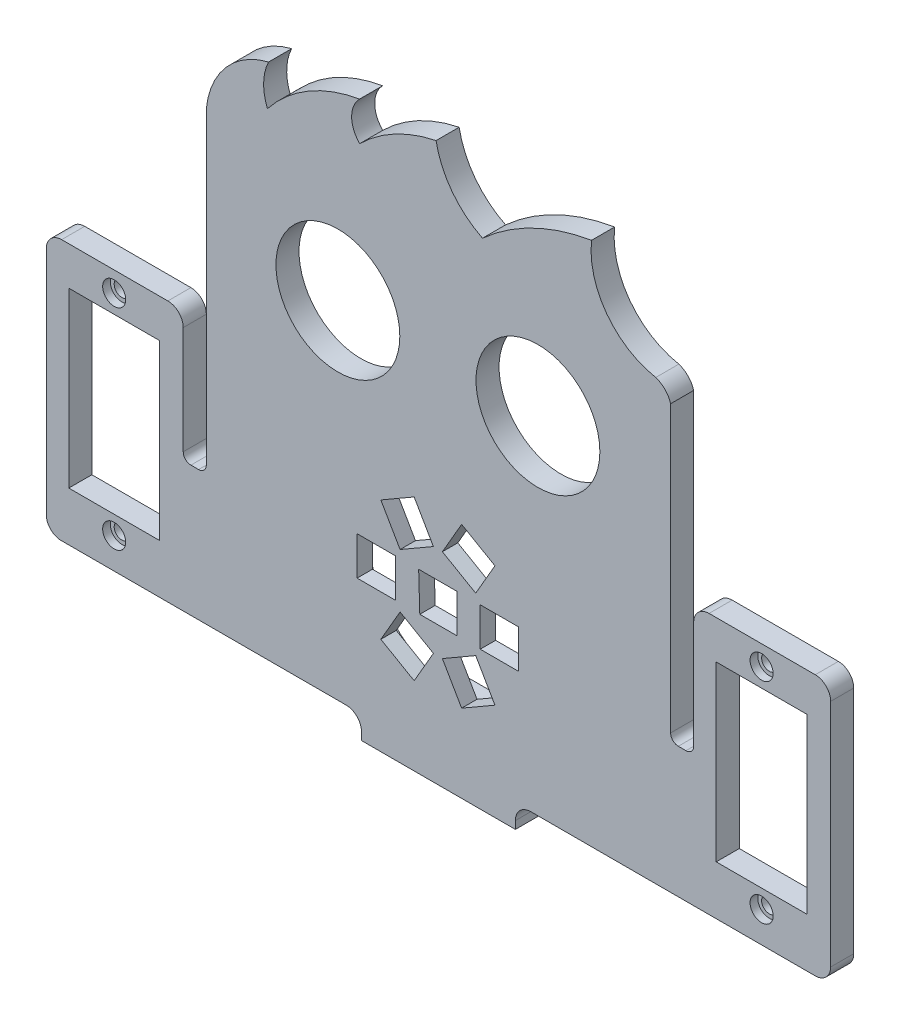
from build123d import *

# Parameters (mm, degrees)
MODEL_R                 = 8.05
MODEL_R_2               = 1
MODEL_W                 = 5
MODEL_H                 = 5
MODEL_W_2               = 11.8
MODEL_H_2               = 22.5
SALIENTE_EXTRUIR1_DEPTH = 3
CROQUIS2_R              = 1.5
CORTAR_EXTRUIR1_DEPTH   = 1
CROQUIS4_W              = 19.999967436
CROQUIS4_H              = 3
SALIENTE_EXTRUIR2_DEPTH = 8
CROQUIS5_R              = 1.5
CORTAR_EXTRUIR2_DEPTH   = 3
REDONDEO1_R             = 2
CROQUIS6_R              = 12
CORTAR_EXTRUIR3_DEPTH   = 1


with BuildPart() as part:
    # Model → Saliente-Extruir1 (new body)
    with BuildSketch(Plane.XY):
        with BuildLine():
            Line((28.600020379, -36.098945331), (29.600020379, -36.098945331))
            ThreePointArc((29.600020379, -36.098945331), (30.307127161, -35.806052112), (30.600020379, -35.098945331))
            Line((30.600020379, -35.098945331), (30.600020379, 4.974420659))
            ThreePointArc((30.600020379, 4.974420659), (33.150320304, 10.94136051), (38.69115159, 14.318872844))
            ThreePointArc((38.69115159, 14.318872844), (38.049426695, 11.673196605), (38.544127303, 8.99613013))
            ThreePointArc((38.544127303, 8.99613013), (43.872924224, 13.634815248), (50.51172433, 16.051385009))
            ThreePointArc((50.51172433, 16.051385009), (49.487728366, 13.546636971), (50.534778199, 11.051438157))
            ThreePointArc((50.534778199, 11.051438157), (55.112285588, 14.426569266), (60.460332405, 16.361376528))
            ThreePointArc((60.460332405, 16.361376528), (62.537747107, 11.66270114), (66.497154818, 8.389126209))
            ThreePointArc((66.497154818, 8.389126209), (73.089038309, 12.831206377), (80.665288642, 15.236499516))
            ThreePointArc((80.665288642, 15.236499516), (82.62970299, 7.967186508), (89.013428278, 3.973455574))
            ThreePointArc((89.013428278, 3.973455574), (90.223089011, 3.212884764), (90.943701038, 1.979002536))
            Line((90.943701038, 1.979002536), (90.943701038, -35.070997464))
            ThreePointArc((90.943701038, -35.070997464), (91.236594257, -35.778104245), (91.943701038, -36.070997464))
            Line((91.943701038, -36.070997464), (92.943701038, -36.070997464))
            ThreePointArc((92.943701038, -36.070997464), (93.650807819, -35.778104245), (93.943701038, -35.070997464))
            Line((93.943701038, -35.070997464), (93.943701038, -21.120997464))
            ThreePointArc((93.943701038, -21.120997464), (94.529487475, -19.706783901), (95.943701038, -19.120997464))
            Line((95.943701038, -19.120997464), (109.743701038, -19.120997464))
            ThreePointArc((109.743701038, -19.120997464), (111.1579146, -19.706783901), (111.743701038, -21.120997464))
            Line((111.743701038, -21.120997464), (111.743701038, -51.020997464))
            ThreePointArc((111.743701038, -51.020997464), (111.1579146, -52.435211026), (109.743701038, -53.020997464))
            Line((109.743701038, -53.020997464), (72.771860709, -53.020997464))
            ThreePointArc((72.771860709, -53.020997464), (71.357647146, -53.606783901), (70.771860709, -55.020997464))
            Line((70.771860709, -55.020997464), (70.771860709, -56.020573856))
            Line((70.771860709, -56.020573856), (50.771893273, -56.020573856))
            Line((50.771893273, -56.020573856), (50.771882418, -55.020552149))
            ThreePointArc((50.771882418, -55.020552149), (50.186088306, -53.606352619), (48.771882419, -53.020573857))
            Line((48.771882419, -53.020573857), (11.743679941, -53.020573857))
            ThreePointArc((11.743679941, -53.020573857), (10.369303805, -52.451275514), (9.800020379, -51.076893199))
            Line((9.800020379, -51.076893199), (9.800020379, -21.120997464))
            ThreePointArc((9.800020379, -21.120997464), (10.385806817, -19.706783901), (11.800020379, -19.120997464))
            Line((11.800020379, -19.120997464), (25.600020379, -19.120997464))
            ThreePointArc((25.600020379, -19.120997464), (27.014233942, -19.706783901), (27.600020379, -21.120997464))
            Line((27.600020379, -21.120997464), (27.600020379, -35.098945331))
            ThreePointArc((27.600020379, -35.098945331), (27.892913598, -35.806052112), (28.600020379, -36.098945331))
        make_face()
        with Locations((47.698959583, -8.020997464)):
            Circle(MODEL_R, mode=Mode.SUBTRACT)
        with Locations((73.698959582, -8.020997464)):
            Circle(MODEL_R, mode=Mode.SUBTRACT)
        with Locations((102.770799912, -49.020997464)):
            Circle(MODEL_R_2, mode=Mode.SUBTRACT)
        with Locations((102.770799912, -21.720997464)):
            Circle(MODEL_R_2, mode=Mode.SUBTRACT)
        with Locations((18.627119253, -49.020997464)):
            Circle(MODEL_R_2, mode=Mode.SUBTRACT)
        with Locations((18.627119253, -21.720997464)):
            Circle(MODEL_R_2, mode=Mode.SUBTRACT)
        Polygon((53.283896073, -43.364264203), (57.614023092, -45.864264203), (60.114023092, -41.534137185), (55.783896073, -39.034137185), align=None, mode=Mode.SUBTRACT)
        Polygon((63.783896073, -45.864264204), (68.114023092, -43.364264204), (65.614023092, -39.034137185), (61.283896073, -41.534137185), align=None, mode=Mode.SUBTRACT)
        with Locations((68.698959582, -35.520997464)):
            Rectangle(MODEL_W, MODEL_H, mode=Mode.SUBTRACT)
        Polygon((68.114023092, -27.677730724), (63.783896073, -25.177730724), (61.283896073, -29.507857743), (65.614023092, -32.007857743), align=None, mode=Mode.SUBTRACT)
        Polygon((57.614023092, -25.177730724), (53.283896073, -27.677730724), (55.783896073, -32.007857743), (60.114023092, -29.507857743), align=None, mode=Mode.SUBTRACT)
        with Locations((52.698959582, -35.520997464)):
            Rectangle(MODEL_W, MODEL_H, mode=Mode.SUBTRACT)
        Polygon((58.198975864, -33.020997464), (58.344778117, -38.020997464), (63.198975864, -38.020997464), (63.198975864, -33.020997464), align=None, mode=Mode.SUBTRACT)
        with Locations((102.770799912, -35.370997464)):
            Rectangle(MODEL_W_2, MODEL_H_2, mode=Mode.SUBTRACT)
        with Locations((18.627119253, -35.370997464)):
            Rectangle(MODEL_W_2, MODEL_H_2, mode=Mode.SUBTRACT)
    extrude(amount=SALIENTE_EXTRUIR1_DEPTH)

    # Croquis2 → Cortar-Extruir1 (cut)
    with BuildSketch(Plane.XY.offset(3)):
        with Locations((18.627119253, -21.720997464)):
            Circle(CROQUIS2_R)
        with Locations((18.627119253, -49.020997464)):
            Circle(CROQUIS2_R)
        with Locations((102.770799912, -49.020997464)):
            Circle(CROQUIS2_R)
        with Locations((102.770799912, -21.720997464)):
            Circle(CROQUIS2_R)
    extrude(amount=-CORTAR_EXTRUIR1_DEPTH, mode=Mode.SUBTRACT)

    # Croquis4 → Saliente-Extruir2 (add)
    with BuildSketch(Plane(origin=(0, 0, 0), x_dir=(-1, 0, 0), z_dir=(0, 0, -1))):
        with Locations((-60.771876991, -54.520573856)):
            Rectangle(CROQUIS4_W, CROQUIS4_H)
    extrude(amount=SALIENTE_EXTRUIR2_DEPTH)

    # Croquis5 → Cortar-Extruir2 (cut)
    with BuildSketch(Plane(origin=(0, -53.020573856, 0), x_dir=(1, 0, 0), z_dir=(0, 1, 0))):
        with Locations((66.771876991, 3.5)):
            Circle(CROQUIS5_R)
        with Locations((54.771876991, 3.5)):
            Circle(CROQUIS5_R)
    extrude(amount=-CORTAR_EXTRUIR2_DEPTH, mode=Mode.SUBTRACT)

    # Redondeo1
    redondeo1_edges = [part.edges().sort_by_distance(p)[0] for p in [
        (50.771893273, -54.520573856, -8),
        (70.771860709, -54.520573856, -8),
    ]]
    fillet(redondeo1_edges, radius=REDONDEO1_R)

    # Croquis6 → Cortar-Extruir3 (cut)
    with BuildSketch(Plane(origin=(0, 0, 0), x_dir=(-1, 0, 0), z_dir=(0, 0, -1))):
        with Locations((-60.771860709, -35.520573857)):
            Circle(CROQUIS6_R)
    extrude(amount=-CORTAR_EXTRUIR3_DEPTH, mode=Mode.SUBTRACT)


solid = part.part
